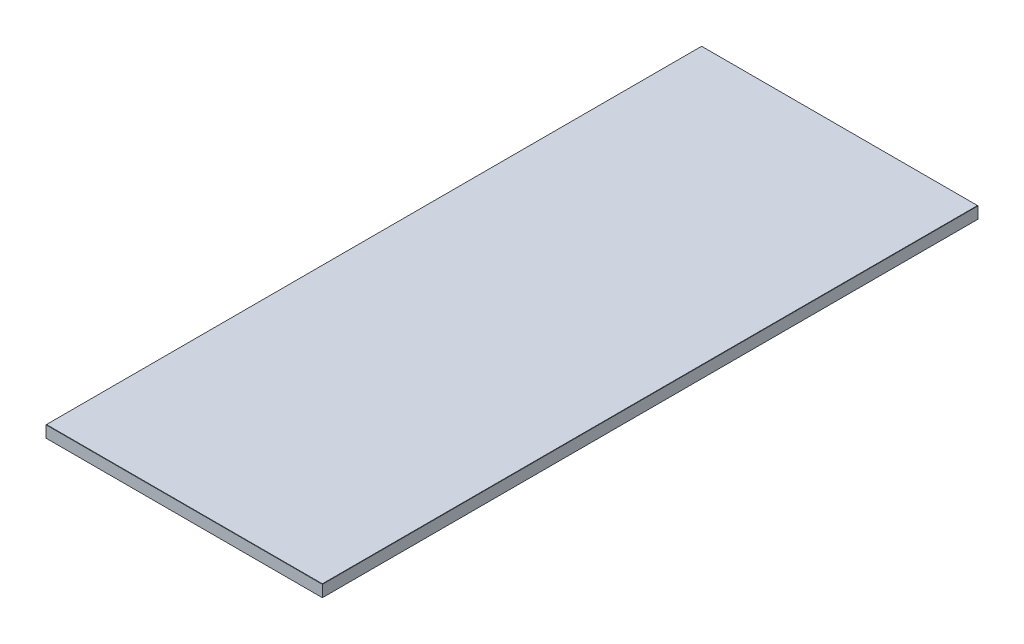
from build123d import *

# Parameters (mm, degrees)
SKETCH1_W           = 274
SKETCH1_H           = 650
BOSS_EXTRUDE1_DEPTH = 12
CHAMFER1_SIZE       = 0.25


with BuildPart() as part:
    # Sketch1 → Boss-Extrude1 (new body)
    with BuildSketch(Plane(origin=(0, 0, 0), x_dir=(1, 0, 0), z_dir=(0, 1, 0))):
        Rectangle(SKETCH1_W, SKETCH1_H)
    extrude(amount=BOSS_EXTRUDE1_DEPTH)

    # Chamfer1
    chamfer1_edges = [part.edges().sort_by_distance(p)[0] for p in [
        (-137, 12, 0),
        (0, 12, 325),
        (137, 12, 0),
        (0, 0, 325),
        (-137, 0, 0),
        (0, 0, -325),
        (137, 0, 0),
        (0, 12, -325),
    ]]
    chamfer(chamfer1_edges, length=CHAMFER1_SIZE)


solid = part.part
